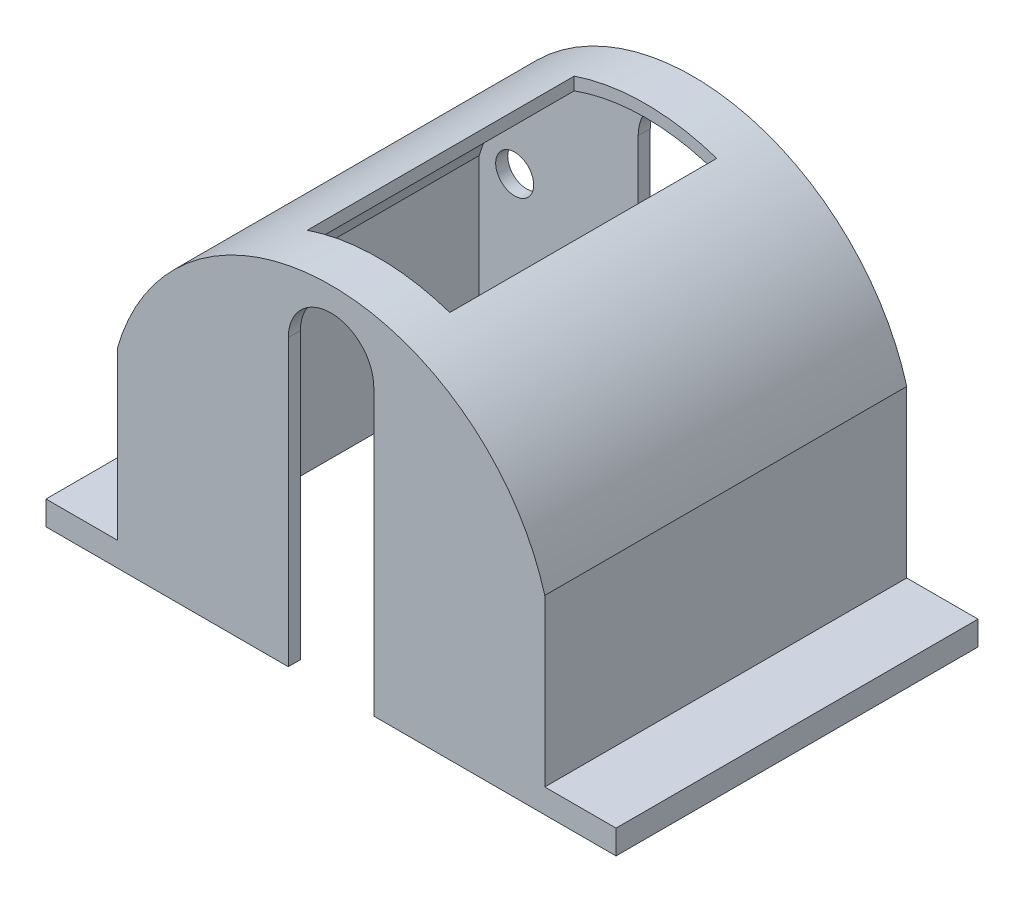
from build123d import *

# Parameters (mm, degrees)
BOSS_EXTRUDE3_DEPTH     = 38.1
SHELL1_T                = -1.27
CUT_EXTRUDE1_DEPTH      = 39.1
SKETCH4_R               = 2
CUT_EXTRUDE2_DEPTH      = 2.54
SKETCH5_W               = 15
SKETCH5_H               = 28.1
CUT_EXTRUDE3_DEPTH      = 18.025
CUT_EXTRUDE3_DEPTH_BACK = 21
SKETCH6_W               = 7.5
SKETCH6_H               = 38.1
BOSS_EXTRUDE4_DEPTH     = 2.54


with BuildPart() as part:
    # Sketch1 → Boss-Extrude3 (new body)
    with BuildSketch(Plane.XY):
        with BuildLine():
            Line((-22.5, 0), (-22.5, -20))
            Line((-22.5, -20), (22.5, -20))
            Line((22.5, -20), (22.5, 0))
            ThreePointArc((22.5, 0), (0, 17.025), (-22.5, 0))
        make_face()
    extrude(amount=BOSS_EXTRUDE3_DEPTH)

    # Shell1
    shell1_openings = [part.faces().sort_by_distance(p)[0] for p in [
        (0, -20, 19.05),
    ]]
    offset(amount=SHELL1_T, openings=shell1_openings, kind=Kind.INTERSECTION)

    # Sketch3 → Cut-Extrude1 (cut, through all)
    with BuildSketch(Plane(origin=(0, 0, 0), x_dir=(-1, 0, 0), z_dir=(0, 0, -1))):
        with BuildLine():
            Line((-4.5, 10), (-4.5, -20))
            Line((-4.5, -20), (4.5, -20))
            Line((4.5, -20), (4.5, 10))
            ThreePointArc((4.5, 10), (0, 14.5), (-4.5, 10))
        make_face()
    extrude(amount=-CUT_EXTRUDE1_DEPTH, mode=Mode.SUBTRACT)

    # Sketch4 → Cut-Extrude2 (cut)
    with BuildSketch(Plane(origin=(0, 0, 0), x_dir=(-1, 0, 0), z_dir=(0, 0, -1))):
        with Locations((-17.5, 0)):
            Circle(SKETCH4_R)
        with Locations((17.5, 0)):
            Circle(SKETCH4_R)
    extrude(amount=-CUT_EXTRUDE2_DEPTH, mode=Mode.SUBTRACT)

    # Sketch5 → Cut-Extrude3 (cut, two sides)
    with BuildSketch(Plane(origin=(0, 0, 0), x_dir=(1, 0, 0), z_dir=(0, 1, 0))) as cut_extrude3_sk:
        with Locations((0, -19.05)):
            Rectangle(SKETCH5_W, SKETCH5_H)
    extrude(amount=CUT_EXTRUDE3_DEPTH, mode=Mode.SUBTRACT)
    extrude(cut_extrude3_sk.sketch, amount=-CUT_EXTRUDE3_DEPTH_BACK, mode=Mode.SUBTRACT)

    # Sketch6 → Boss-Extrude4 (add)
    with BuildSketch(Plane.XZ.offset(20)):
        with Locations((-26.25, 19.05)):
            Rectangle(SKETCH6_W, SKETCH6_H)
        with Locations((26.25, 19.05)):
            Rectangle(SKETCH6_W, SKETCH6_H)
    extrude(amount=-BOSS_EXTRUDE4_DEPTH)


solid = part.part
